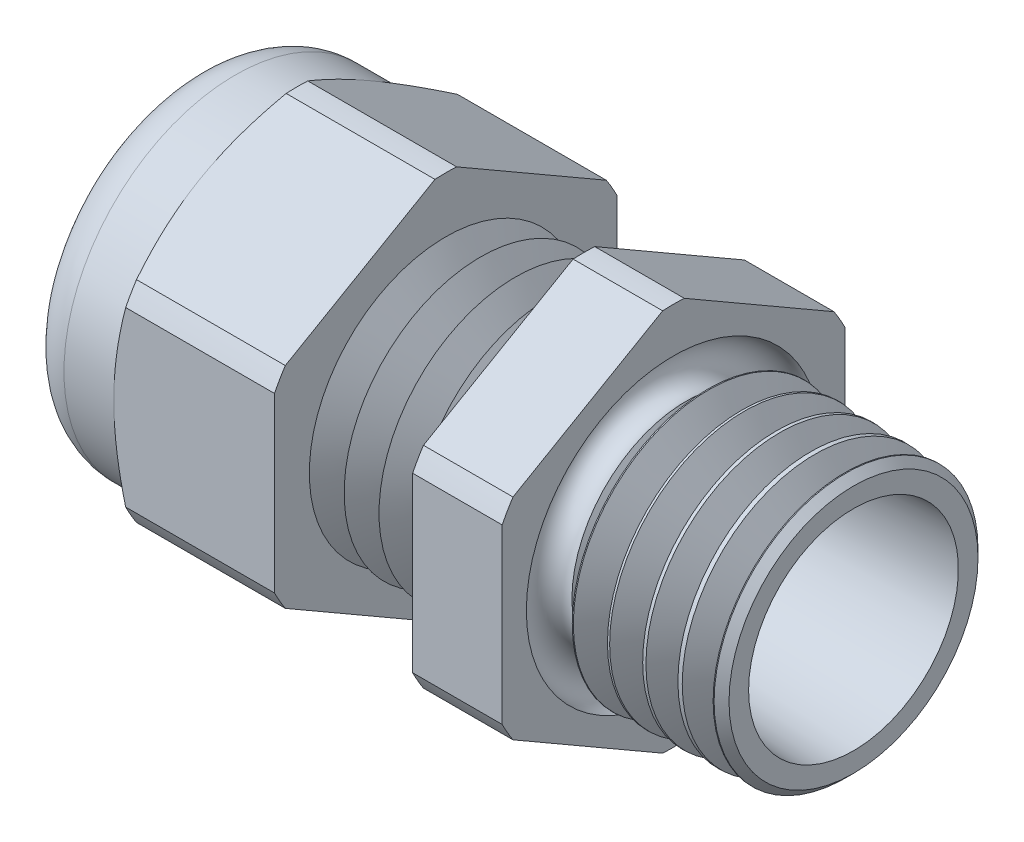
from build123d import *

# Parameters (mm, degrees)
SKETCH2_OUTSIDE_W  = 26.272
SKETCH2_OUTSIDE_H  = 26.272
CUT_EXTRUDE1_DEPTH = 16.98625
CHAMFER1_SIZE      = 0.326149358
CHAMFER1_SIZE2     = 0.3175
SKETCH3_OUTSIDE_W  = 113.902
SKETCH3_OUTSIDE_H  = 115.7
SKETCH3_OUTSIDE_R  = 7.493
CUT_EXTRUDE2_DEPTH = 25.86025
CUT_EXTRUDE2_DRAFT = -60
SKETCH14_W         = 4.09575
SKETCH14_H         = 1.524
FILLET1_R          = 1.91516
LPATTERN1_COUNT    = 4
LPATTERN1_PITCH    = 1.524
LPATTERN2_COUNT    = 6
LPATTERN2_PITCH    = 1.524
SKETCH15_R         = 0.8255


with BuildPart() as part:
    # Sketch1 → Revolve1 (revolve)
    with BuildSketch(Plane.XY, mode=Mode.PRIVATE) as revolve1_sk:
        Polygon((-9.958916667, 5.969), (-9.958916667, 8.39216), (-16.98625, 8.39216), (-16.98625, 5.969), (-21.082, 5.969), (-21.082, 5.07365), (-16.98625, 5.07365), (-16.98625, 3.81), (-9.958916667, 3.81), (7.874, 4.588601956), (7.874, 5.762812054), (0, 5.969), (0, 8.39216), (-3.917412935, 8.39216), (-3.917412935, 5.969), align=None)
    revolve(revolve1_sk.sketch.rotate(Axis((-18.386021217, 0, 0), (1, 0, 0)), 90), axis=Axis((-18.386021217, 0, 0), (1, 0, 0)))  # turned: the seam where the file's is

    # Sketch2 outside → Cut-Extrude1 (cut)
    with BuildSketch(Plane(origin=(0, 0, 0), x_dir=(0, 0, -1), z_dir=(1, 0, 0))):
        Rectangle(SKETCH2_OUTSIDE_W, SKETCH2_OUTSIDE_H)
        with BuildLine():
            Line((7.493, -3.779325398), (7.493, 3.779325398))
            ThreePointArc((7.493, 3.779325398), (7.267823753, 4.19608), (7.019491804, 4.599465651))
            Line((7.019491804, 4.599465651), (0.473508196, 8.37879105))
            ThreePointArc((0.473508196, 8.37879105), (0, 8.39216), (-0.473508196, 8.37879105))
            Line((-0.473508196, 8.37879105), (-7.019491804, 4.599465651))
            ThreePointArc((-7.019491804, 4.599465651), (-7.267823753, 4.19608), (-7.493, 3.779325398))
            Line((-7.493, 3.779325398), (-7.493, -3.779325398))
            ThreePointArc((-7.493, -3.779325398), (-7.267823753, -4.19608), (-7.019491804, -4.599465651))
            Line((-7.019491804, -4.599465651), (-0.473508196, -8.37879105))
            ThreePointArc((-0.473508196, -8.37879105), (0, -8.39216), (0.473508196, -8.37879105))
            Line((0.473508196, -8.37879105), (7.019491804, -4.599465651))
            ThreePointArc((7.019491804, -4.599465651), (7.267823753, -4.19608), (7.493, -3.779325398))
        make_face(mode=Mode.SUBTRACT)
    extrude(amount=-CUT_EXTRUDE1_DEPTH, mode=Mode.SUBTRACT)

    # Chamfer1
    chamfer1_edges = [part.edges().sort_by_distance(p)[0] for p in [
        (7.874, 0, -5.762812054),
    ]]
    chamfer1_side = [part.faces().sort_by_distance(p)[0] for p in [
        (3.937, 0, -5.865906027),
    ]]
    chamfer(chamfer1_edges, length=CHAMFER1_SIZE, length2=CHAMFER1_SIZE2, reference=chamfer1_side[0])


with BuildPart() as cut_extrude2_tool:
    # Sketch3 outside → Cut-Extrude2 (with draft: the straight prism first)
    with BuildSketch(Plane.ZY.offset(16.98625)):
        Rectangle(SKETCH3_OUTSIDE_W, SKETCH3_OUTSIDE_H)
        Circle(SKETCH3_OUTSIDE_R, mode=Mode.SUBTRACT)
    extrude(amount=-CUT_EXTRUDE2_DEPTH)
    # Cut-Extrude2: the draft: its side faces are tilted about the plane it starts from
    cut_extrude2_sides = [cut_extrude2_tool.faces().sort_by_distance(p)[0] for p in [
        (-4.056125, -57.85, 0),
        (-4.056125, 0, 56.951),
        (-4.056125, 57.85, 0),
        (-4.056125, 0, -56.951),
        (-4.056125, 0, -7.493),
    ]]
    draft(cut_extrude2_sides, Plane.ZY.offset(16.98625), CUT_EXTRUDE2_DRAFT)


with BuildPart() as part_1:
    add(part.part)

    # Cut-Extrude2: cut by cut_extrude2_tool
    add(cut_extrude2_tool.part, mode=Mode.SUBTRACT)

    # Sketch14 → Revolve4 (revolve)
    with BuildSketch(Plane.XY, mode=Mode.PRIVATE) as revolve4_sk:
        with Locations((-19.034125, 6.731)):
            Rectangle(SKETCH14_W, SKETCH14_H)
    revolve(revolve4_sk.sketch.rotate(Axis((-18.386021217, 0, 0), (1, 0, 0)), 90), axis=Axis((-18.386021217, 0, 0), (1, 0, 0)))  # turned: the seam where the file's is

    # Fillet1
    fillet1_edges = [part_1.edges().sort_by_distance(p)[0] for p in [
        (-21.082, 0, -7.493),
    ]]
    fillet(fillet1_edges, radius=FILLET1_R)

    # Sketch10 → Cut-Revolve1 (revolve, cut)
    with BuildSketch(Plane.XY, mode=Mode.PRIVATE) as cut_revolve1_sk:
        Polygon((-9.958916667, 5.969), (-9.196917022, 4.6491779), (-8.434917377, 5.969), align=None)
    cut_revolve1 = revolve(cut_revolve1_sk.sketch.rotate(Axis((15.58962545, 0, 0), (-1, 0, 0)), 90), axis=Axis((15.58962545, 0, 0), (-1, 0, 0)), mode=Mode.SUBTRACT)  # turned: the seam where the file's is

    # LPattern1: Cut-Revolve1 ×4
    with Locations(*[(i * LPATTERN1_PITCH, 0, 0) for i in range(1, LPATTERN1_COUNT)]):
        add(cut_revolve1, mode=Mode.SUBTRACT)

    # Sketch13 → Cut-Revolve2 (revolve, cut)
    with BuildSketch(Plane.XY, mode=Mode.PRIVATE) as cut_revolve2_sk:
        Polygon((0, 5.969), (1.523999289, 5.969), (0.761999645, 4.6491779), align=None)
    cut_revolve2 = revolve(cut_revolve2_sk.sketch.rotate(Axis((-18.386021217, 0, 0), (1, 0, 0)), 270), axis=Axis((-18.386021217, 0, 0), (1, 0, 0)), mode=Mode.SUBTRACT)  # turned: the seam where the file's is

    # LPattern2: Cut-Revolve2 ×6
    with Locations(*[(i * LPATTERN2_PITCH, 0, 0) for i in range(1, LPATTERN2_COUNT)]):
        add(cut_revolve2, mode=Mode.SUBTRACT)

    # Sketch15 → Cut-Revolve3 (revolve, cut)
    with BuildSketch(Plane.XY, mode=Mode.PRIVATE) as cut_revolve3_sk:
        with Locations((0, -5.609698712)):
            Circle(SKETCH15_R)
    revolve(cut_revolve3_sk.sketch.rotate(Axis((1.524, 0, 0), (-1, 0, 0)), 90), axis=Axis((1.524, 0, 0), (-1, 0, 0)), mode=Mode.SUBTRACT)  # turned: the seam where the file's is


with BuildPart() as body_2:
    # Sketch9 → Revolve3 (revolve)
    with BuildSketch(Plane.XY, mode=Mode.PRIVATE) as revolve3_sk:
        with BuildLine():
            Line((-20.32, 3.81), (-20.32, 4.81965))
            ThreePointArc((-20.32, 4.81965), (-20.245605122, 4.999255122), (-20.066, 5.07365))
            Line((-20.066, 5.07365), (-16.98625, 5.07365))
            Line((-16.98625, 5.07365), (-16.98625, 3.81))
            Line((-16.98625, 3.81), (-20.32, 3.81))
        make_face()
    revolve(revolve3_sk.sketch.rotate(Axis((8.695207459, 0, 0), (-1, 0, 0)), 270), axis=Axis((8.695207459, 0, 0), (-1, 0, 0)))  # turned: the seam where the file's is


solid = Compound([part_1.part, body_2.part])
